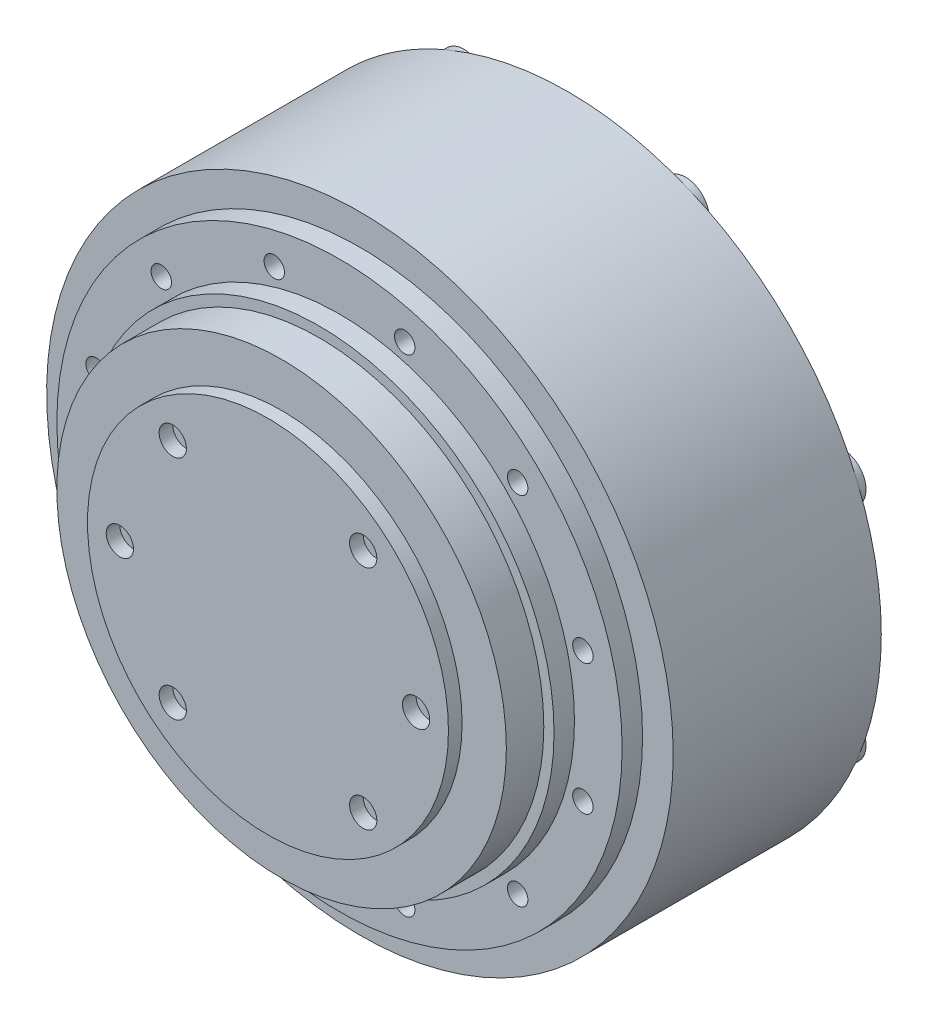
from build123d import *

# Parameters (mm, degrees)
SKETCH_1_R      = 46
EXTRUDE_1_DEPTH = 30.55
SKETCH_3_R      = 3.5
SKETCH_3_R_2    = 1.75
EXTRUDE_2_DEPTH = 1
SKETCH_4_R      = 41.5
SKETCH_4_R_2    = 1.5
EXTRUDE_3_DEPTH = 3
SKETCH_5_R      = 33
EXTRUDE_4_DEPTH = 8.5
SKETCH_6_R      = 26.5
SKETCH_6_R_2    = 2
EXTRUDE_5_DEPTH = 2
SKETCH_7_R      = 34.5
EXTRUDE_6_DEPTH = 3
SKETCH_8_W      = 20
SKETCH_8_H      = 10
EXTRUDE_7_DEPTH = 5


with BuildPart() as part:
    # 草图1 → 凸台-拉伸1 (new body)
    with BuildSketch(Plane.XY):
        Circle(SKETCH_1_R)
    extrude(amount=EXTRUDE_1_DEPTH)

    # 草图3 → 凸台-拉伸2 (add)
    with BuildSketch(Plane(origin=(0, 0, 0), x_dir=(-1, 0, 0), z_dir=(0, 0, -1))):
        with Locations((16.264045876, 39.264880132)):
            Circle(SKETCH_3_R)
        with Locations((16.264045876, 39.264880132)):
            Circle(SKETCH_3_R_2, mode=Mode.SUBTRACT)
        with Locations((39.264880132, 16.264045876)):
            Circle(SKETCH_3_R)
        with Locations((39.264880132, 16.264045876)):
            Circle(SKETCH_3_R_2, mode=Mode.SUBTRACT)
        with Locations((39.264880132, -16.264045876)):
            Circle(SKETCH_3_R)
        with Locations((39.264880132, -16.264045876)):
            Circle(SKETCH_3_R_2, mode=Mode.SUBTRACT)
        with Locations((16.264045876, -39.264880132)):
            Circle(SKETCH_3_R)
        with Locations((16.264045876, -39.264880132)):
            Circle(SKETCH_3_R_2, mode=Mode.SUBTRACT)
        with Locations((-16.264045876, -39.264880132)):
            Circle(SKETCH_3_R)
        with Locations((-16.264045876, -39.264880132)):
            Circle(SKETCH_3_R_2, mode=Mode.SUBTRACT)
        with Locations((-39.264880132, -16.264045876)):
            Circle(SKETCH_3_R)
        with Locations((-39.264880132, -16.264045876)):
            Circle(SKETCH_3_R_2, mode=Mode.SUBTRACT)
        with Locations((-39.264880132, 16.264045876)):
            Circle(SKETCH_3_R)
        with Locations((-39.264880132, 16.264045876)):
            Circle(SKETCH_3_R_2, mode=Mode.SUBTRACT)
        with Locations((-16.264045876, 39.264880132)):
            Circle(SKETCH_3_R)
        with Locations((-16.264045876, 39.264880132)):
            Circle(SKETCH_3_R_2, mode=Mode.SUBTRACT)
    extrude(amount=EXTRUDE_2_DEPTH)

    # 草图4 → 凸台-拉伸3 (add)
    with BuildSketch(Plane.XY.offset(30.55)):
        Circle(SKETCH_4_R)
        with Locations((26.162950904, 26.162950904)):
            Circle(SKETCH_4_R_2, mode=Mode.SUBTRACT)
        with Locations((35.739255573, 9.576304669)):
            Circle(SKETCH_4_R_2, mode=Mode.SUBTRACT)
        with Locations((35.739255573, -9.576304669)):
            Circle(SKETCH_4_R_2, mode=Mode.SUBTRACT)
        with Locations((26.162950904, -26.162950904)):
            Circle(SKETCH_4_R_2, mode=Mode.SUBTRACT)
        with Locations((9.576304669, -35.739255573)):
            Circle(SKETCH_4_R_2, mode=Mode.SUBTRACT)
        with Locations((-9.576304669, -35.739255573)):
            Circle(SKETCH_4_R_2, mode=Mode.SUBTRACT)
        with Locations((-26.162950904, -26.162950904)):
            Circle(SKETCH_4_R_2, mode=Mode.SUBTRACT)
        with Locations((-35.739255573, -9.576304669)):
            Circle(SKETCH_4_R_2, mode=Mode.SUBTRACT)
        with Locations((-35.739255573, 9.576304669)):
            Circle(SKETCH_4_R_2, mode=Mode.SUBTRACT)
        with Locations((-26.162950904, 26.162950904)):
            Circle(SKETCH_4_R_2, mode=Mode.SUBTRACT)
        with Locations((-9.576304669, 35.739255573)):
            Circle(SKETCH_4_R_2, mode=Mode.SUBTRACT)
        with Locations((9.576304669, 35.739255573)):
            Circle(SKETCH_4_R_2, mode=Mode.SUBTRACT)
    extrude(amount=EXTRUDE_3_DEPTH)

    # 草图5 → 凸台-拉伸4 (add)
    with BuildSketch(Plane.XY.offset(33.55)):
        Circle(SKETCH_5_R)
    extrude(amount=EXTRUDE_4_DEPTH)

    # 草图6 → 凸台-拉伸5 (add)
    with BuildSketch(Plane.XY.offset(42.05)):
        Circle(SKETCH_6_R)
        with Locations((-13.980630511, -16.661466638)):
            Circle(SKETCH_6_R_2, mode=Mode.SUBTRACT)
        with Locations((-21.75, 0)):
            Circle(SKETCH_6_R_2, mode=Mode.SUBTRACT)
        with Locations((-13.980630511, 16.661466638)):
            Circle(SKETCH_6_R_2, mode=Mode.SUBTRACT)
        with Locations((13.980630511, -16.661466638)):
            Circle(SKETCH_6_R_2, mode=Mode.SUBTRACT)
        with Locations((21.75, 0)):
            Circle(SKETCH_6_R_2, mode=Mode.SUBTRACT)
        with Locations((13.980630511, 16.661466638)):
            Circle(SKETCH_6_R_2, mode=Mode.SUBTRACT)
    extrude(amount=EXTRUDE_5_DEPTH)

    # 草图7 → 凸台-拉伸6 (add)
    with BuildSketch(Plane.XY.offset(33.55)):
        Circle(SKETCH_7_R)
    extrude(amount=EXTRUDE_6_DEPTH)

    # 草图8 → 凸台-拉伸7 (add)
    with BuildSketch(Plane(origin=(0, 0, 0), x_dir=(-1, 0, 0), z_dir=(0, 0, -1))):
        with Locations((-10, 0)):
            Rectangle(SKETCH_8_W, SKETCH_8_H)
    extrude(amount=EXTRUDE_7_DEPTH)


solid = part.part
